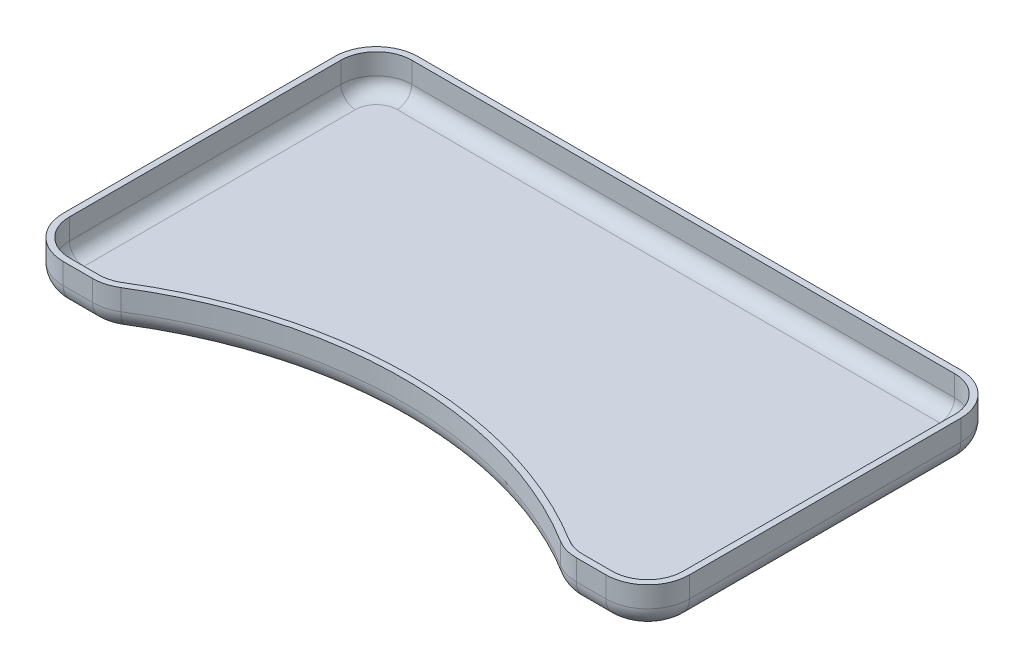
from build123d import *

# Parameters (mm, degrees)
BOSS_EXTRUDE1_DEPTH     = 20
FILLET1_R               = 10
SHELL1_T                = -3
SKETCH2_W               = 3
SKETCH2_H               = 40
BOSS_EXTRUDE2_DEPTH     = 20
SKETCH3_W               = 103
SKETCH3_H               = 40
BOSS_EXTRUDE3_DEPTH     = 3
SKETCH4_R               = 1.5
CUT_EXTRUDE1_DEPTH      = 3
LPATTERN1_COUNT         = 5
LPATTERN1_PITCH         = 10
LPATTERN1_COL_COUNT     = 5
LPATTERN1_COL_PITCH     = 10
MIRROR1_COPY_1_SKETCH_R = 1.5
MIRROR1_COPY_1_DEPTH    = 3
MIRROR1_COPY_2_SKETCH_R = 1.5
MIRROR1_COPY_2_DEPTH    = 3
MIRROR1_COPY_3_SKETCH_R = 1.5
MIRROR1_COPY_3_DEPTH    = 3
MIRROR1_COPY_4_SKETCH_R = 1.5
MIRROR1_COPY_4_DEPTH    = 3
MIRROR1_COPY_5_SKETCH_R = 1.5
MIRROR1_COPY_5_DEPTH    = 3
MIRROR1_COPY_6_SKETCH_R = 1.5
MIRROR1_COPY_6_DEPTH    = 3
MIRROR1_COPY_7_SKETCH_R = 1.5
MIRROR1_COPY_7_DEPTH    = 3
MIRROR1_COPY_8_SKETCH_R = 1.5
MIRROR1_COPY_8_DEPTH    = 3


with BuildPart() as part:
    # Sketch1 → Boss-Extrude1 (new body)
    with BuildSketch(Plane(origin=(0, 0, 0), x_dir=(1, 0, 0), z_dir=(0, 1, 0))):
        with BuildLine():
            Line((115.839038172, -85), (130, -85))
            ThreePointArc((130, -85), (144.142135624, -79.142135624), (150, -65))
            Line((150, -65), (150, 65))
            ThreePointArc((150, 65), (144.142135624, 79.142135624), (130, 85))
            Line((130, 85), (-130, 85))
            ThreePointArc((-130, 85), (-144.142135624, 79.142135624), (-150, 65))
            Line((-150, 65), (-150, -65))
            ThreePointArc((-150, -65), (-144.142135624, -79.142135624), (-130, -85))
            Line((-130, -85), (-115.839038172, -85))
            ThreePointArc((-115.839038172, -85), (-110.364546156, -84.236162226), (-105.30821652, -82.002993717))
            ThreePointArc((-105.30821652, -82.002993717), (0, -52.032930885), (105.30821652, -82.002993717))
            ThreePointArc((105.30821652, -82.002993717), (110.364546156, -84.236162226), (115.839038172, -85))
        make_face()
    extrude(amount=BOSS_EXTRUDE1_DEPTH)

    # Fillet1
    fillet1_edges = [part.edges().sort_by_distance(p)[0] for p in [
        (-150, 0, 0),
        (-144.142135624, 0, -79.142135624),
        (0, 0, -85),
        (144.142135624, 0, -79.142135624),
        (150, 0, 0),
        (144.142135624, 0, 79.142135624),
        (122.919519086, 0, 85),
        (110.364546156, 0, 84.236162226),
        (0, 0, 52.032930885),
        (-110.364546156, 0, 84.236162226),
        (-122.919519086, 0, 85),
        (-144.142135624, 0, 79.142135624),
    ]]
    fillet(fillet1_edges, radius=FILLET1_R)

    # Shell1
    shell1_openings = [part.faces().sort_by_distance(p)[0] for p in [
        (0, 20, 25.458771278),
    ]]
    offset(amount=SHELL1_T, openings=shell1_openings, kind=Kind.INTERSECTION)

    # Sketch2 → Boss-Extrude2 (add)
    with BuildSketch(Plane.XZ):
        with Locations((50, 0)):
            Rectangle(SKETCH2_W, SKETCH2_H)
        with Locations((-50, 0)):
            Rectangle(SKETCH2_W, SKETCH2_H)
    extrude(amount=BOSS_EXTRUDE2_DEPTH)

    # Sketch3 → Boss-Extrude3 (add)
    with BuildSketch(Plane.XZ.offset(20)):
        Rectangle(SKETCH3_W, SKETCH3_H)
    extrude(amount=BOSS_EXTRUDE3_DEPTH)

    # Sketch4 → Cut-Extrude1 (cut)
    with BuildSketch(Plane.XZ.offset(23)):
        with Locations((0, 15)):
            Circle(SKETCH4_R)
    cut_extrude1 = extrude(amount=-CUT_EXTRUDE1_DEPTH, mode=Mode.SUBTRACT)

    # LPattern1: Cut-Extrude1 ×5
    with Locations(*[(i * LPATTERN1_PITCH, 0, 0) for i in range(1, LPATTERN1_COUNT)]):
        add(cut_extrude1, mode=Mode.SUBTRACT)

    # LPattern1 col: Cut-Extrude1 ×5
    with Locations(*[(-i * LPATTERN1_COL_PITCH, 0, 0) for i in range(1, LPATTERN1_COL_COUNT)]):
        add(cut_extrude1, mode=Mode.SUBTRACT)

    # Mirror1: Cut-Extrude1 across plane
    add(cut_extrude1.mirror(Plane.XY), mode=Mode.SUBTRACT)

    # Mirror1 copy 1 sketch → Mirror1 copy 1 (cut)
    with BuildSketch(Plane(origin=(10, -23, 0), x_dir=(1, 0, 0), z_dir=(0, -1, 0))):
        with Locations((0, -15)):
            Circle(MIRROR1_COPY_1_SKETCH_R)
    extrude(amount=-MIRROR1_COPY_1_DEPTH, mode=Mode.SUBTRACT)

    # Mirror1 copy 2 sketch → Mirror1 copy 2 (cut)
    with BuildSketch(Plane(origin=(20, -23, 0), x_dir=(1, 0, 0), z_dir=(0, -1, 0))):
        with Locations((0, -15)):
            Circle(MIRROR1_COPY_2_SKETCH_R)
    extrude(amount=-MIRROR1_COPY_2_DEPTH, mode=Mode.SUBTRACT)

    # Mirror1 copy 3 sketch → Mirror1 copy 3 (cut)
    with BuildSketch(Plane(origin=(30, -23, 0), x_dir=(1, 0, 0), z_dir=(0, -1, 0))):
        with Locations((0, -15)):
            Circle(MIRROR1_COPY_3_SKETCH_R)
    extrude(amount=-MIRROR1_COPY_3_DEPTH, mode=Mode.SUBTRACT)

    # Mirror1 copy 4 sketch → Mirror1 copy 4 (cut)
    with BuildSketch(Plane(origin=(40, -23, 0), x_dir=(1, 0, 0), z_dir=(0, -1, 0))):
        with Locations((0, -15)):
            Circle(MIRROR1_COPY_4_SKETCH_R)
    extrude(amount=-MIRROR1_COPY_4_DEPTH, mode=Mode.SUBTRACT)

    # Mirror1 copy 5 sketch → Mirror1 copy 5 (cut)
    with BuildSketch(Plane(origin=(-10, -23, 0), x_dir=(1, 0, 0), z_dir=(0, -1, 0))):
        with Locations((0, -15)):
            Circle(MIRROR1_COPY_5_SKETCH_R)
    extrude(amount=-MIRROR1_COPY_5_DEPTH, mode=Mode.SUBTRACT)

    # Mirror1 copy 6 sketch → Mirror1 copy 6 (cut)
    with BuildSketch(Plane(origin=(-20, -23, 0), x_dir=(1, 0, 0), z_dir=(0, -1, 0))):
        with Locations((0, -15)):
            Circle(MIRROR1_COPY_6_SKETCH_R)
    extrude(amount=-MIRROR1_COPY_6_DEPTH, mode=Mode.SUBTRACT)

    # Mirror1 copy 7 sketch → Mirror1 copy 7 (cut)
    with BuildSketch(Plane(origin=(-30, -23, 0), x_dir=(1, 0, 0), z_dir=(0, -1, 0))):
        with Locations((0, -15)):
            Circle(MIRROR1_COPY_7_SKETCH_R)
    extrude(amount=-MIRROR1_COPY_7_DEPTH, mode=Mode.SUBTRACT)

    # Mirror1 copy 8 sketch → Mirror1 copy 8 (cut)
    with BuildSketch(Plane(origin=(-40, -23, 0), x_dir=(1, 0, 0), z_dir=(0, -1, 0))):
        with Locations((0, -15)):
            Circle(MIRROR1_COPY_8_SKETCH_R)
    extrude(amount=-MIRROR1_COPY_8_DEPTH, mode=Mode.SUBTRACT)


solid = part.part
